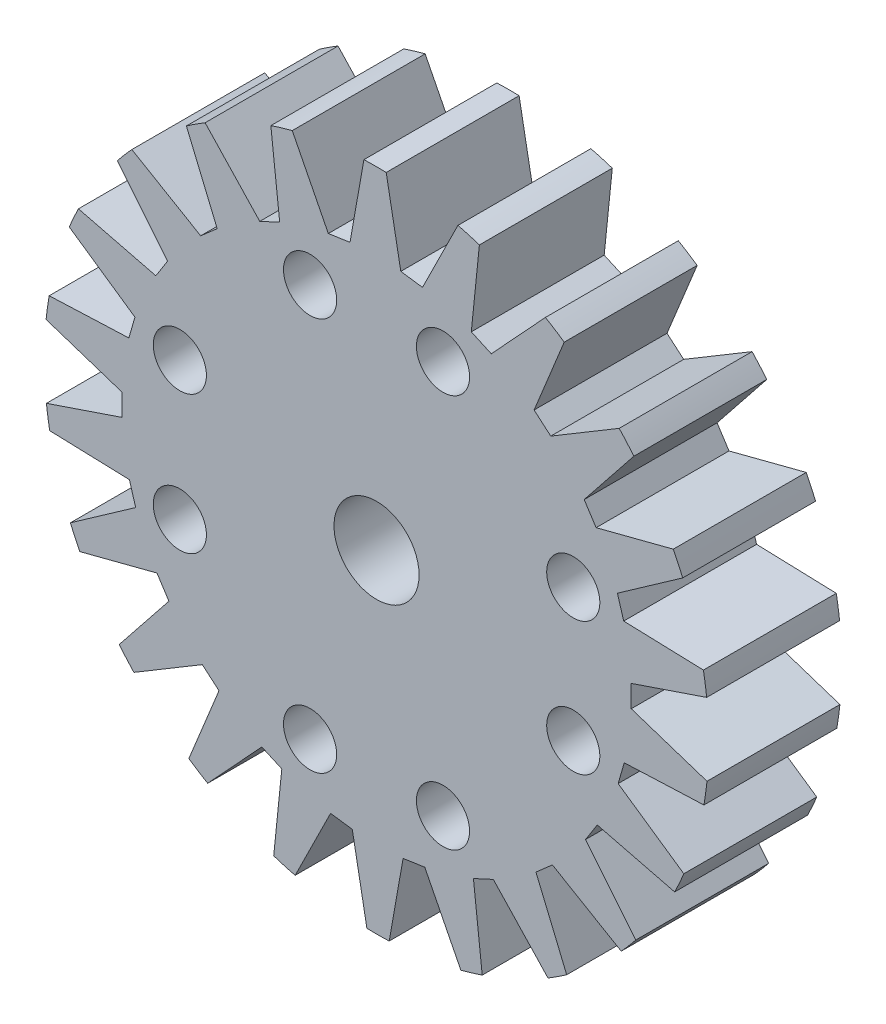
from build123d import *

# Parameters (mm, degrees)
SKETCH1_R           = 12.5
SKETCH1_R_2         = 1.6
SKETCH1_R_3         = 1
BOSS_EXTRUDE1_DEPTH = 5
CUT_EXTRUDE1_DEPTH  = 6
CIRPATTERN1_COUNT   = 22


with BuildPart() as part:
    # Sketch1 → Boss-Extrude1 (new body)
    with BuildSketch(Plane.XY):
        Circle(SKETCH1_R)
        Circle(SKETCH1_R_2, mode=Mode.SUBTRACT)
        with Locations((2.5, -7.4)):
            Circle(SKETCH1_R_3, mode=Mode.SUBTRACT)
        with Locations((-2.5, -7.4)):
            Circle(SKETCH1_R_3, mode=Mode.SUBTRACT)
        with Locations((7.4, -2.5)):
            Circle(SKETCH1_R_3, mode=Mode.SUBTRACT)
        with Locations((-7.4, -2.694035424)):
            Circle(SKETCH1_R_3, mode=Mode.SUBTRACT)
        with Locations((-7.4, 2.5)):
            Circle(SKETCH1_R_3, mode=Mode.SUBTRACT)
        with Locations((-2.5, 7.4)):
            Circle(SKETCH1_R_3, mode=Mode.SUBTRACT)
        with Locations((2.5, 7.4)):
            Circle(SKETCH1_R_3, mode=Mode.SUBTRACT)
        with Locations((7.4, 2.5)):
            Circle(SKETCH1_R_3, mode=Mode.SUBTRACT)
    extrude(amount=BOSS_EXTRUDE1_DEPTH)

    # Sketch2 → Cut-Extrude1 (cut, through all)
    with BuildSketch(Plane.XY.offset(5)):
        Polygon((-9.204992805, 8.456837911), (-6.616673599, 6.940063806), (-5.995627184, 7.483135026), (-7.153657676, 10.250618608), (-7.456074993, 10.596457577), (-9.507410122, 8.80267688), align=None)
    cut_extrude1 = extrude(amount=-CUT_EXTRUDE1_DEPTH, mode=Mode.SUBTRACT)

    # CirPattern1: Cut-Extrude1 ×22 about axis
    cirpattern1_axis = Axis((0, 0, 0), (0, 0, 1))
    for i in range(1, CIRPATTERN1_COUNT):
        add(cut_extrude1.rotate(cirpattern1_axis, i * 360 / CIRPATTERN1_COUNT), mode=Mode.SUBTRACT)


solid = part.part
